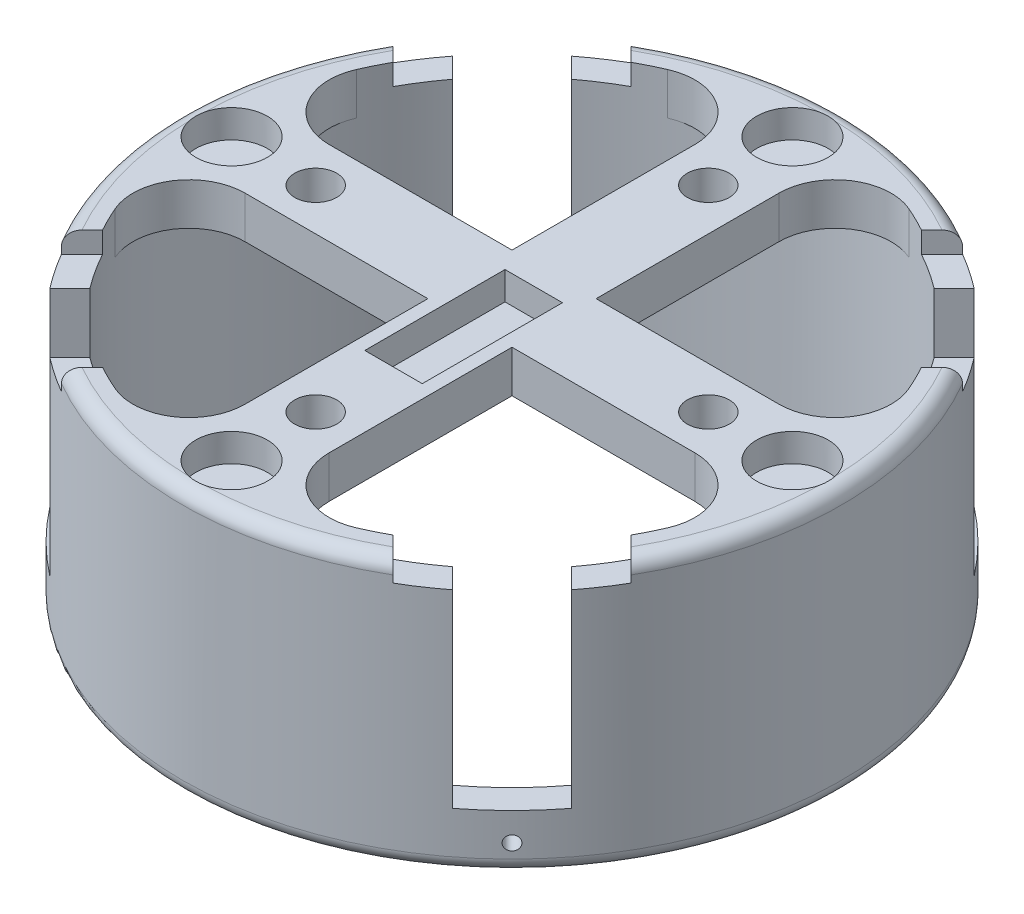
from build123d import *

# Parameters (mm, degrees)
SKETCH5_R           = 23.5
SKETCH5_R_2         = 21.5
BOSS_EXTRUDE3_DEPTH = 19
SKETCH6_R           = 1.5
BOSS_EXTRUDE4_DEPTH = 3
CIRPATTERN1_COUNT   = 4
FILLET1_R           = 4
CUT_EXTRUDE1_DEPTH  = 15
CIRPATTERN2_COUNT   = 4
CUT_EXTRUDE2_DEPTH  = 1.5
CIRPATTERN3_COUNT   = 4
FILLET2_R           = 1
FILLET3_R           = 1
CUT_EXTRUDE3_START  = -0.192276
SKETCH9_R           = 0.5
CUT_EXTRUDE3_DEPTH  = 2.005815
CIRPATTERN4_COUNT   = 4
SKETCH10_R          = 2.55
CUT_EXTRUDE4_DEPTH  = 2
CIRPATTERN5_COUNT   = 4
SKETCH11_W          = 4.1
SKETCH11_H          = 10
CUT_EXTRUDE5_DEPTH  = 2


with BuildPart() as part:
    # Sketch5 → Boss-Extrude3 (new body)
    with BuildSketch(Plane(origin=(0, 0, 0), x_dir=(1, 0, 0), z_dir=(0, 1, 0))):
        Circle(SKETCH5_R)
        Circle(SKETCH5_R_2, mode=Mode.SUBTRACT)
    extrude(amount=BOSS_EXTRUDE3_DEPTH)

    # Sketch6 → Boss-Extrude4 (add)
    with BuildSketch(Plane(origin=(0, 19, 0), x_dir=(1, 0, 0), z_dir=(0, 1, 0))):
        with BuildLine():
            Line((-3, 0), (-3, 21.289668856))
            ThreePointArc((-3, 21.289668856), (0, 21.5), (3, 21.289668856))
            Line((3, 21.289668856), (3, 0))
            Line((3, 0), (-3, 0))
        make_face()
        with Locations((0, 14)):
            Circle(SKETCH6_R, mode=Mode.SUBTRACT)
    boss_extrude4 = extrude(amount=-BOSS_EXTRUDE4_DEPTH)

    # CirPattern1: Boss-Extrude4 ×4 about axis
    cirpattern1_axis = Axis((0, 0, 0), (0, 1, 0))
    for i in range(1, CIRPATTERN1_COUNT):
        add(boss_extrude4.rotate(cirpattern1_axis, i * 360 / CIRPATTERN1_COUNT))

    # Fillet1
    fillet1_edges = [part.edges().sort_by_distance(p)[0] for p in [
        (-3, 17.5, -21.289668856),
        (3, 17.5, -21.289668856),
        (-21.289668856, 17.5, -3),
        (-21.289668856, 17.5, 3),
        (3, 17.5, 21.289668856),
        (-3, 17.5, 21.289668856),
        (21.289668856, 17.5, -3),
        (21.289668856, 17.5, 3),
    ]]
    fillet(fillet1_edges, radius=FILLET1_R)

    # Sketch7 → Cut-Extrude1 (cut)
    with BuildSketch(Plane(origin=(0, 19, 0), x_dir=(1, 0, 0), z_dir=(0, 1, 0))):
        Polygon((21.341935675, 17.099294988), (16.134723728, 11.892083041), (11.892083041, 16.134723728), (17.099294988, 21.341935675), align=None)
    cut_extrude1 = extrude(amount=-CUT_EXTRUDE1_DEPTH, mode=Mode.SUBTRACT)

    # CirPattern2: Cut-Extrude1 ×4 about axis
    cirpattern2_axis = Axis((0, 0, 0), (0, 1, 0))
    for i in range(1, CIRPATTERN2_COUNT):
        add(cut_extrude1.rotate(cirpattern2_axis, i * 360 / CIRPATTERN2_COUNT), mode=Mode.SUBTRACT)

    # Sketch8 → Cut-Extrude2 (cut)
    with BuildSketch(Plane(origin=(0, 19, 0), x_dir=(1, 0, 0), z_dir=(0, 1, 0))):
        Polygon((-12.859793573, 21.345074947), (-7.348880887, 15.834162262), (-15.834162262, 7.348880887), (-21.345074947, 12.859793573), align=None)
    cut_extrude2 = extrude(amount=-CUT_EXTRUDE2_DEPTH, mode=Mode.SUBTRACT)

    # CirPattern3: Cut-Extrude2 ×4 about axis
    cirpattern3_axis = Axis((0, 0, 0), (0, 1, 0))
    for i in range(1, CIRPATTERN3_COUNT):
        add(cut_extrude2.rotate(cirpattern3_axis, i * 360 / CIRPATTERN3_COUNT), mode=Mode.SUBTRACT)

    # Fillet2
    fillet2_edges = [part.edges().sort_by_distance(p)[0] for p in [
        (-23.5, 19, 0),
        (0, 19, -23.5),
        (22.688205944, 19, -6.123341492),
        (0, 19, 23.5),
    ]]
    fillet(fillet2_edges, radius=FILLET2_R)

    # Fillet3
    fillet3_edges = [part.edges().sort_by_distance(p)[0] for p in [
        (-23.5, 0, 0),
    ]]
    fillet(fillet3_edges, radius=FILLET3_R)

    # Sketch9 → Cut-Extrude3 (cut)
    with BuildSketch(Plane(origin=(-16.481049724, 0, 16.481049724), x_dir=(-0.707106781, 0, -0.707106781), z_dir=(0.707106781, 0, -0.707106781)).offset(CUT_EXTRUDE3_START)):
        with Locations((0, 2)):
            Circle(SKETCH9_R)
    cut_extrude3 = extrude(amount=CUT_EXTRUDE3_DEPTH, mode=Mode.SUBTRACT)

    # CirPattern4: Cut-Extrude3 ×4 about axis
    cirpattern4_axis = Axis((0, 19, 0), (0, -1, 0))
    for i in range(1, CIRPATTERN4_COUNT):
        add(cut_extrude3.rotate(cirpattern4_axis, i * 360 / CIRPATTERN4_COUNT), mode=Mode.SUBTRACT)

    # Sketch10 → Cut-Extrude4 (cut)
    with BuildSketch(Plane(origin=(0, 19, 0), x_dir=(1, 0, 0), z_dir=(0, 1, 0))):
        with Locations((0, 20)):
            Circle(SKETCH10_R)
    cut_extrude4 = extrude(amount=-CUT_EXTRUDE4_DEPTH, mode=Mode.SUBTRACT)

    # CirPattern5: Cut-Extrude4 ×4 about axis
    cirpattern5_axis = Axis((0, 0, 0), (0, 1, 0))
    for i in range(1, CIRPATTERN5_COUNT):
        add(cut_extrude4.rotate(cirpattern5_axis, i * 360 / CIRPATTERN5_COUNT), mode=Mode.SUBTRACT)

    # Sketch11 → Cut-Extrude5 (cut)
    with BuildSketch(Plane(origin=(0, 19, 0), x_dir=(1, 0, 0), z_dir=(0, 1, 0))):
        with Locations((0, -3.45)):
            Rectangle(SKETCH11_W, SKETCH11_H)
    extrude(amount=-CUT_EXTRUDE5_DEPTH, mode=Mode.SUBTRACT)


solid = part.part
